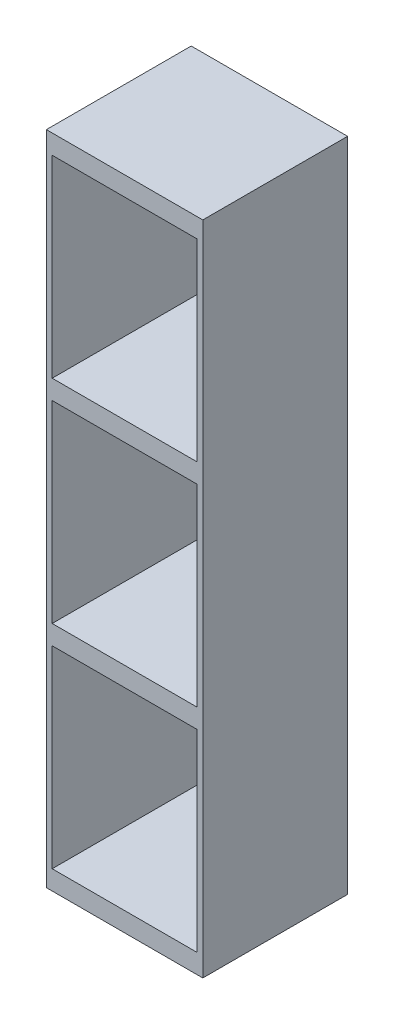
from build123d import *

# Parameters (mm, degrees)
SKETCH3_W           = 75
SKETCH3_H           = 75
BOSS_EXTRUDE2_DEPTH = 10
LPATTERN1_COUNT     = 4
LPATTERN1_PITCH     = 110
SKETCH3_5_W         = 3
SKETCH3_5_H         = 75
BOSS_EXTRUDE5_DEPTH = 340


with BuildPart() as part:
    # Sketch3 → Boss-Extrude2 (new body)
    with BuildSketch(Plane(origin=(0, 0, 0), x_dir=(1, 0, 0), z_dir=(0, 1, 0))):
        Rectangle(SKETCH3_W, SKETCH3_H)
    extrude(amount=BOSS_EXTRUDE2_DEPTH)


with BuildPart() as lpattern1_1:
    # LPattern1: pattern copy
    add(part.part.moved(Location(Vector(0, 1, 0) * (1 * LPATTERN1_PITCH))))


with BuildPart() as lpattern1_2:
    # LPattern1: pattern copy
    add(part.part.moved(Location(Vector(0, 1, 0) * (2 * LPATTERN1_PITCH))))


with BuildPart() as lpattern1_3:
    # LPattern1: pattern copy
    add(part.part.moved(Location(Vector(0, 1, 0) * (3 * LPATTERN1_PITCH))))


with BuildPart() as part_1:
    add(part.part)

    add(lpattern1_1.part)  # Boss-Extrude5 merges LPattern1_1

    add(lpattern1_2.part)  # Boss-Extrude5 merges LPattern1_2

    add(lpattern1_3.part)  # Boss-Extrude5 merges LPattern1_3
    # Sketch3_5 → Boss-Extrude5 (add)
    with BuildSketch(Plane(origin=(0, 0, 0), x_dir=(1, 0, 0), z_dir=(0, 1, 0))):
        with Locations((-39, 0)):
            Rectangle(SKETCH3_5_W, SKETCH3_5_H)
        with Locations((39, 0)):
            Rectangle(SKETCH3_5_W, SKETCH3_5_H)
    extrude(amount=BOSS_EXTRUDE5_DEPTH)


solid = part_1.part
